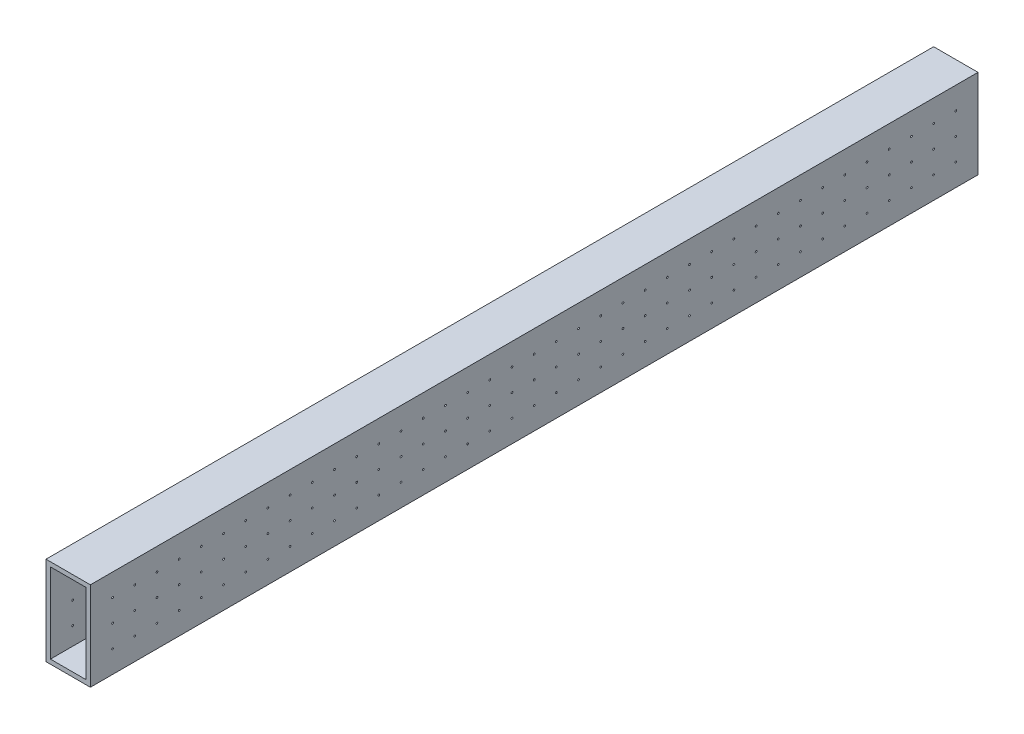
from build123d import *

# Parameters (mm, degrees)
SKETCH1_W               = 25.4
SKETCH1_H               = 50.8
SKETCH1_W_2             = 20.32
SKETCH1_H_2             = 45.72
BOSS_EXTRUDE1_DEPTH     = 508
SKETCH2_R               = 0.5
CUT_EXTRUDE1_DEPTH      = 1
CUT_EXTRUDE1_DEPTH_BACK = 26.4


with BuildPart() as part:
    # Sketch1 → Boss-Extrude1 (new body)
    with BuildSketch(Plane.XY):
        with Locations((49.989361702, -2.161702128)):
            Rectangle(SKETCH1_W, SKETCH1_H)
        with Locations((49.989361702, -2.161702128)):
            Rectangle(SKETCH1_W_2, SKETCH1_H_2, mode=Mode.SUBTRACT)
    extrude(amount=BOSS_EXTRUDE1_DEPTH)

    # Sketch2 → Cut-Extrude1 (cut, two sides)
    with BuildSketch(Plane.ZY.offset(-37.289361702)) as cut_extrude1_sk:
        with Locations((12.7, 10.538297872)):
            Circle(SKETCH2_R)
        with Locations((25.4, 10.538297872)):
            Circle(SKETCH2_R)
        with Locations((38.1, 10.538297872)):
            Circle(SKETCH2_R)
        with Locations((50.8, 10.538297872)):
            Circle(SKETCH2_R)
        with Locations((63.5, 10.538297872)):
            Circle(SKETCH2_R)
        with Locations((76.2, 10.538297872)):
            Circle(SKETCH2_R)
        with Locations((88.9, 10.538297872)):
            Circle(SKETCH2_R)
        with Locations((101.6, 10.538297872)):
            Circle(SKETCH2_R)
        with Locations((114.3, 10.538297872)):
            Circle(SKETCH2_R)
        with Locations((127, 10.538297872)):
            Circle(SKETCH2_R)
        with Locations((139.7, 10.538297872)):
            Circle(SKETCH2_R)
        with Locations((152.4, 10.538297872)):
            Circle(SKETCH2_R)
        with Locations((165.1, 10.538297872)):
            Circle(SKETCH2_R)
        with Locations((177.8, 10.538297872)):
            Circle(SKETCH2_R)
        with Locations((190.5, 10.538297872)):
            Circle(SKETCH2_R)
        with Locations((203.2, 10.538297872)):
            Circle(SKETCH2_R)
        with Locations((215.9, 10.538297872)):
            Circle(SKETCH2_R)
        with Locations((228.6, 10.538297872)):
            Circle(SKETCH2_R)
        with Locations((241.3, 10.538297872)):
            Circle(SKETCH2_R)
        with Locations((254, 10.538297872)):
            Circle(SKETCH2_R)
        with Locations((266.7, 10.538297872)):
            Circle(SKETCH2_R)
        with Locations((279.4, 10.538297872)):
            Circle(SKETCH2_R)
        with Locations((292.1, 10.538297872)):
            Circle(SKETCH2_R)
        with Locations((304.8, 10.538297872)):
            Circle(SKETCH2_R)
        with Locations((317.5, 10.538297872)):
            Circle(SKETCH2_R)
        with Locations((330.2, 10.538297872)):
            Circle(SKETCH2_R)
        with Locations((342.9, 10.538297872)):
            Circle(SKETCH2_R)
        with Locations((355.6, 10.538297872)):
            Circle(SKETCH2_R)
        with Locations((368.3, 10.538297872)):
            Circle(SKETCH2_R)
        with Locations((381, 10.538297872)):
            Circle(SKETCH2_R)
        with Locations((393.7, 10.538297872)):
            Circle(SKETCH2_R)
        with Locations((406.4, 10.538297872)):
            Circle(SKETCH2_R)
        with Locations((419.1, 10.538297872)):
            Circle(SKETCH2_R)
        with Locations((431.8, 10.538297872)):
            Circle(SKETCH2_R)
        with Locations((444.5, 10.538297872)):
            Circle(SKETCH2_R)
        with Locations((457.2, 10.538297872)):
            Circle(SKETCH2_R)
        with Locations((469.9, 10.538297872)):
            Circle(SKETCH2_R)
        with Locations((482.6, 10.538297872)):
            Circle(SKETCH2_R)
        with Locations((495.3, 10.538297872)):
            Circle(SKETCH2_R)
        with Locations((25.4, -2.161702128)):
            Circle(SKETCH2_R)
        with Locations((38.1, -2.161702128)):
            Circle(SKETCH2_R)
        with Locations((50.8, -2.161702128)):
            Circle(SKETCH2_R)
        with Locations((63.5, -2.161702128)):
            Circle(SKETCH2_R)
        with Locations((76.2, -2.161702128)):
            Circle(SKETCH2_R)
        with Locations((88.9, -2.161702128)):
            Circle(SKETCH2_R)
        with Locations((101.6, -2.161702128)):
            Circle(SKETCH2_R)
        with Locations((114.3, -2.161702128)):
            Circle(SKETCH2_R)
        with Locations((127, -2.161702128)):
            Circle(SKETCH2_R)
        with Locations((139.7, -2.161702128)):
            Circle(SKETCH2_R)
        with Locations((152.4, -2.161702128)):
            Circle(SKETCH2_R)
        with Locations((165.1, -2.161702128)):
            Circle(SKETCH2_R)
        with Locations((177.8, -2.161702128)):
            Circle(SKETCH2_R)
        with Locations((190.5, -2.161702128)):
            Circle(SKETCH2_R)
        with Locations((203.2, -2.161702128)):
            Circle(SKETCH2_R)
        with Locations((215.9, -2.161702128)):
            Circle(SKETCH2_R)
        with Locations((228.6, -2.161702128)):
            Circle(SKETCH2_R)
        with Locations((241.3, -2.161702128)):
            Circle(SKETCH2_R)
        with Locations((254, -2.161702128)):
            Circle(SKETCH2_R)
        with Locations((266.7, -2.161702128)):
            Circle(SKETCH2_R)
        with Locations((279.4, -2.161702128)):
            Circle(SKETCH2_R)
        with Locations((292.1, -2.161702128)):
            Circle(SKETCH2_R)
        with Locations((304.8, -2.161702128)):
            Circle(SKETCH2_R)
        with Locations((317.5, -2.161702128)):
            Circle(SKETCH2_R)
        with Locations((330.2, -2.161702128)):
            Circle(SKETCH2_R)
        with Locations((342.9, -2.161702128)):
            Circle(SKETCH2_R)
        with Locations((355.6, -2.161702128)):
            Circle(SKETCH2_R)
        with Locations((368.3, -2.161702128)):
            Circle(SKETCH2_R)
        with Locations((381, -2.161702128)):
            Circle(SKETCH2_R)
        with Locations((393.7, -2.161702128)):
            Circle(SKETCH2_R)
        with Locations((406.4, -2.161702128)):
            Circle(SKETCH2_R)
        with Locations((419.1, -2.161702128)):
            Circle(SKETCH2_R)
        with Locations((431.8, -2.161702128)):
            Circle(SKETCH2_R)
        with Locations((444.5, -2.161702128)):
            Circle(SKETCH2_R)
        with Locations((457.2, -2.161702128)):
            Circle(SKETCH2_R)
        with Locations((469.9, -2.161702128)):
            Circle(SKETCH2_R)
        with Locations((482.6, -2.161702128)):
            Circle(SKETCH2_R)
        with Locations((495.3, -2.161702128)):
            Circle(SKETCH2_R)
        with Locations((25.4, -14.861702128)):
            Circle(SKETCH2_R)
        with Locations((38.1, -14.861702128)):
            Circle(SKETCH2_R)
        with Locations((50.8, -14.861702128)):
            Circle(SKETCH2_R)
        with Locations((63.5, -14.861702128)):
            Circle(SKETCH2_R)
        with Locations((76.2, -14.861702128)):
            Circle(SKETCH2_R)
        with Locations((88.9, -14.861702128)):
            Circle(SKETCH2_R)
        with Locations((101.6, -14.861702128)):
            Circle(SKETCH2_R)
        with Locations((114.3, -14.861702128)):
            Circle(SKETCH2_R)
        with Locations((127, -14.861702128)):
            Circle(SKETCH2_R)
        with Locations((139.7, -14.861702128)):
            Circle(SKETCH2_R)
        with Locations((152.4, -14.861702128)):
            Circle(SKETCH2_R)
        with Locations((165.1, -14.861702128)):
            Circle(SKETCH2_R)
        with Locations((177.8, -14.861702128)):
            Circle(SKETCH2_R)
        with Locations((190.5, -14.861702128)):
            Circle(SKETCH2_R)
        with Locations((203.2, -14.861702128)):
            Circle(SKETCH2_R)
        with Locations((215.9, -14.861702128)):
            Circle(SKETCH2_R)
        with Locations((228.6, -14.861702128)):
            Circle(SKETCH2_R)
        with Locations((241.3, -14.861702128)):
            Circle(SKETCH2_R)
        with Locations((254, -14.861702128)):
            Circle(SKETCH2_R)
        with Locations((266.7, -14.861702128)):
            Circle(SKETCH2_R)
        with Locations((279.4, -14.861702128)):
            Circle(SKETCH2_R)
        with Locations((292.1, -14.861702128)):
            Circle(SKETCH2_R)
        with Locations((304.8, -14.861702128)):
            Circle(SKETCH2_R)
        with Locations((317.5, -14.861702128)):
            Circle(SKETCH2_R)
        with Locations((330.2, -14.861702128)):
            Circle(SKETCH2_R)
        with Locations((342.9, -14.861702128)):
            Circle(SKETCH2_R)
        with Locations((355.6, -14.861702128)):
            Circle(SKETCH2_R)
        with Locations((368.3, -14.861702128)):
            Circle(SKETCH2_R)
        with Locations((381, -14.861702128)):
            Circle(SKETCH2_R)
        with Locations((393.7, -14.861702128)):
            Circle(SKETCH2_R)
        with Locations((406.4, -14.861702128)):
            Circle(SKETCH2_R)
        with Locations((419.1, -14.861702128)):
            Circle(SKETCH2_R)
        with Locations((431.8, -14.861702128)):
            Circle(SKETCH2_R)
        with Locations((444.5, -14.861702128)):
            Circle(SKETCH2_R)
        with Locations((457.2, -14.861702128)):
            Circle(SKETCH2_R)
        with Locations((469.9, -14.861702128)):
            Circle(SKETCH2_R)
        with Locations((482.6, -14.861702128)):
            Circle(SKETCH2_R)
        with Locations((495.3, -14.861702128)):
            Circle(SKETCH2_R)
        with Locations((12.7, -2.161702128)):
            Circle(SKETCH2_R)
        with Locations((12.7, -14.861702128)):
            Circle(SKETCH2_R)
    extrude(amount=CUT_EXTRUDE1_DEPTH, mode=Mode.SUBTRACT)
    extrude(cut_extrude1_sk.sketch, amount=-CUT_EXTRUDE1_DEPTH_BACK, mode=Mode.SUBTRACT)


solid = part.part
